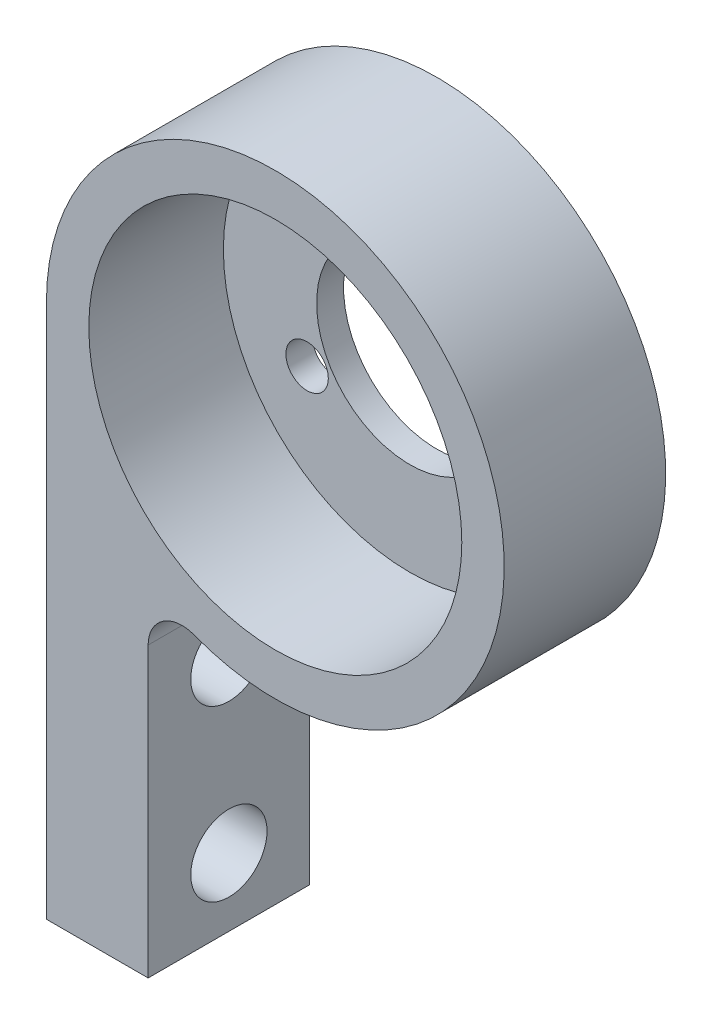
from build123d import *

# Parameters (mm, degrees)
SKETCH2_R             = 13.5
SKETCH2_R_2           = 5.5
SKETCH2_W             = 6
SKETCH2_H             = 31.5
BOSS_EXTRUDE1_DEPTH   = 4.7625
M4_CLEARANCE_HOLE1_D  = 4.5
FILLET1_R             = 2
SKETCH5_R             = 11
CUT_EXTRUDE1_DEPTH    = 7.9375
M3X0_5_TAPPED_HOLE1_D = 2.5


with BuildPart() as part:
    # Sketch2 → Boss-Extrude1 (new body, symmetric)
    with BuildSketch(Plane.XY):
        with Locations((10.5, 15.75)):
            Circle(SKETCH2_R)
        with Locations((10.5, 15.75)):
            Circle(SKETCH2_R_2, mode=Mode.SUBTRACT)
        Rectangle(SKETCH2_W, SKETCH2_H)
    extrude(amount=BOSS_EXTRUDE1_DEPTH, both=True)

    # M4 Clearance Hole1 (through all)
    with Locations(Plane(origin=(3, 0, 0), x_dir=(0, 0, -1), z_dir=(1, 0, 0))):
        with Locations((0, -1.75), (0, -11.75)):
            Hole(M4_CLEARANCE_HOLE1_D / 2)

    # Fillet1
    fillet1_edges = [part.edges().sort_by_distance(p)[0] for p in [
        (3, 4.52502784, 0),
    ]]
    fillet(fillet1_edges, radius=FILLET1_R)

    # Sketch5 → Cut-Extrude1 (cut)
    with BuildSketch(Plane.XY.offset(4.7625)):
        with Locations((10.5, 15.75)):
            Circle(SKETCH5_R)
    extrude(amount=-CUT_EXTRUDE1_DEPTH, mode=Mode.SUBTRACT)

    # M3x0.5 Tapped Hole1 (through all)
    with Locations(Plane(origin=(0, 0, -4.7625), x_dir=(-1, 0, 0), z_dir=(0, 0, -1))):
        with Locations((-10.5, 22.75), (-16.562177826, 12.25), (-4.437822174, 12.25)):
            Hole(M3X0_5_TAPPED_HOLE1_D / 2)


solid = part.part
